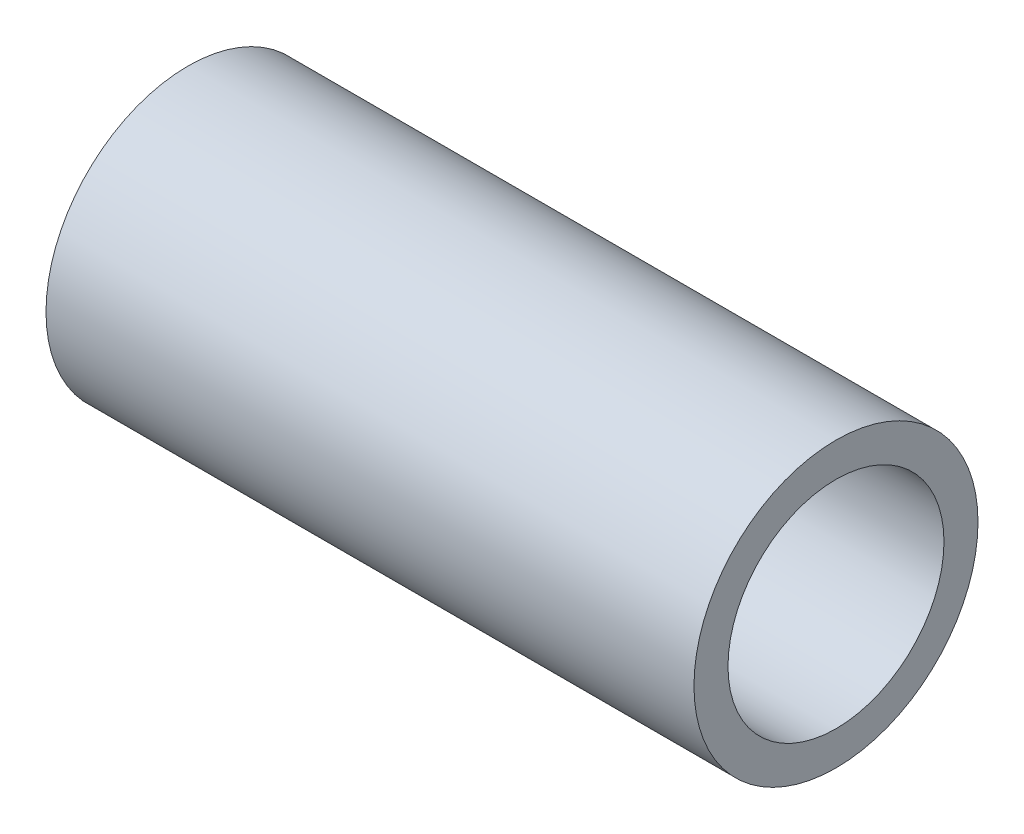
from build123d import *

# Parameters (mm, degrees)
SKETCH1_R           = 16.7005
SKETCH1_R_2         = 12.7
BOSS_EXTRUDE1_DEPTH = 76.2


with BuildPart() as part:
    # Sketch1 → Boss-Extrude1 (new body)
    with BuildSketch(Plane(origin=(0, 0, 0), x_dir=(0, 0, -1), z_dir=(1, 0, 0))):
        Circle(SKETCH1_R)
        Circle(SKETCH1_R_2, mode=Mode.SUBTRACT)
    extrude(amount=BOSS_EXTRUDE1_DEPTH)


solid = part.part
